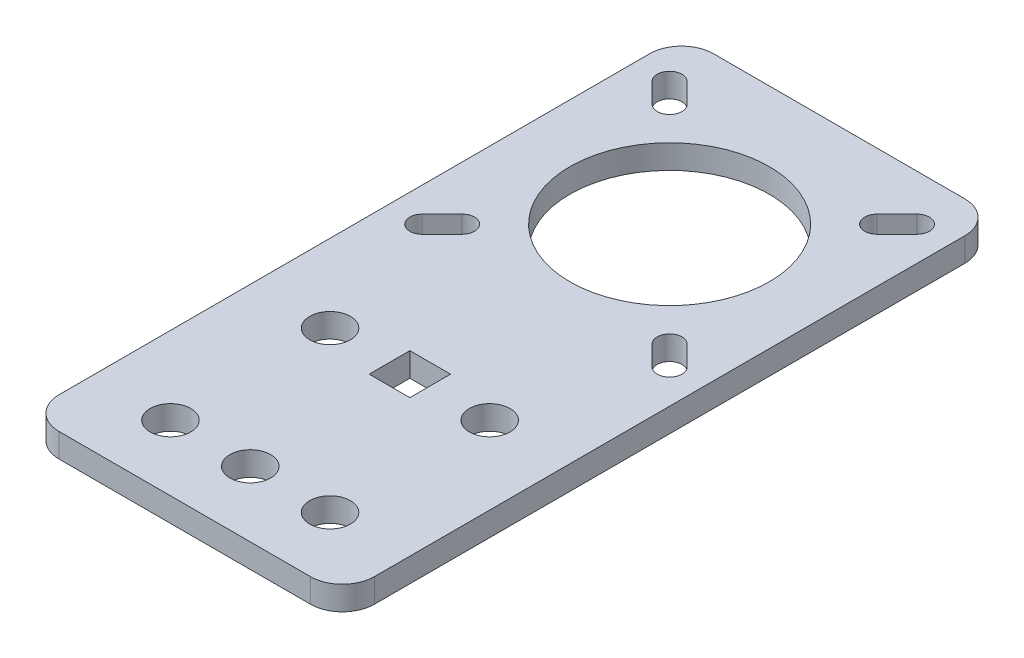
from build123d import *

# Parameters (mm, degrees)
SKETCH1_R           = 12.5
SKETCH1_R_2         = 2.55
BOSS_EXTRUDE1_DEPTH = 3
SKETCH2_W           = 5.1
SKETCH2_H           = 5.1
CUT_EXTRUDE1_DEPTH  = 4


with BuildPart() as part:
    # Sketch1 → Boss-Extrude1 (new body)
    with BuildSketch(Plane(origin=(0, 0, 0), x_dir=(1, 0, 0), z_dir=(0, 1, 0))):
        with BuildLine():
            Line((15.75, -60.75), (-15.75, -60.75))
            ThreePointArc((-15.75, -60.75), (-18.578427125, -59.578427125), (-19.75, -56.75))
            Line((-19.75, -56.75), (-19.75, 17.25))
            ThreePointArc((-19.75, 17.25), (-18.578427125, 20.078427125), (-15.75, 21.25))
            Line((-15.75, 21.25), (15.75, 21.25))
            ThreePointArc((15.75, 21.25), (18.578427125, 20.078427125), (19.75, 17.25))
            Line((19.75, 17.25), (19.75, -56.75))
            ThreePointArc((19.75, -56.75), (18.578427125, -59.578427125), (15.75, -60.75))
        make_face()
        Circle(SKETCH1_R, mode=Mode.SUBTRACT)
        with Locations((10, -52.55)):
            Circle(SKETCH1_R_2, mode=Mode.SUBTRACT)
        with Locations((10, -32.55)):
            Circle(SKETCH1_R_2, mode=Mode.SUBTRACT)
        with Locations((0, -52.55)):
            Circle(SKETCH1_R_2, mode=Mode.SUBTRACT)
        with Locations((0, -32.55)):
            Circle(SKETCH1_R_2, mode=Mode.SUBTRACT)
        with Locations((-10, -52.55)):
            Circle(SKETCH1_R_2, mode=Mode.SUBTRACT)
        with Locations((-10, -32.55)):
            Circle(SKETCH1_R_2, mode=Mode.SUBTRACT)
        with BuildLine():
            Line((11.903984489, 14.096015511), (14.403984489, 16.596015511))
            ThreePointArc((14.403984489, 16.596015511), (16.596015511, 16.596015511), (16.596015511, 14.403984489))
            Line((16.596015511, 14.403984489), (14.096015511, 11.903984489))
            ThreePointArc((14.096015511, 11.903984489), (11.903984489, 11.903984489), (11.903984489, 14.096015511))
        make_face(mode=Mode.SUBTRACT)
        with BuildLine():
            Line((-11.903984489, 14.096015511), (-14.403984489, 16.596015511))
            ThreePointArc((-14.403984489, 16.596015511), (-16.596015511, 16.596015511), (-16.596015511, 14.403984489))
            Line((-16.596015511, 14.403984489), (-14.096015511, 11.903984489))
            ThreePointArc((-14.096015511, 11.903984489), (-11.903984489, 11.903984489), (-11.903984489, 14.096015511))
        make_face(mode=Mode.SUBTRACT)
        with BuildLine():
            Line((-11.903984489, -14.096015511), (-14.403984489, -16.596015511))
            ThreePointArc((-14.403984489, -16.596015511), (-16.596015511, -16.596015511), (-16.596015511, -14.403984489))
            Line((-16.596015511, -14.403984489), (-14.096015511, -11.903984489))
            ThreePointArc((-14.096015511, -11.903984489), (-11.903984489, -11.903984489), (-11.903984489, -14.096015511))
        make_face(mode=Mode.SUBTRACT)
        with BuildLine():
            Line((11.903984489, -14.096015511), (14.403984489, -16.596015511))
            ThreePointArc((14.403984489, -16.596015511), (16.596015511, -16.596015511), (16.596015511, -14.403984489))
            Line((16.596015511, -14.403984489), (14.096015511, -11.903984489))
            ThreePointArc((14.096015511, -11.903984489), (11.903984489, -11.903984489), (11.903984489, -14.096015511))
        make_face(mode=Mode.SUBTRACT)
    extrude(amount=BOSS_EXTRUDE1_DEPTH)

    # Sketch2 → Cut-Extrude1 (cut, through all)
    with BuildSketch(Plane(origin=(0, 3, 0), x_dir=(1, 0, 0), z_dir=(0, 1, 0))):
        with Locations((0, -32.55)):
            Rectangle(SKETCH2_W, SKETCH2_H)
    extrude(amount=-CUT_EXTRUDE1_DEPTH, mode=Mode.SUBTRACT)


solid = part.part
